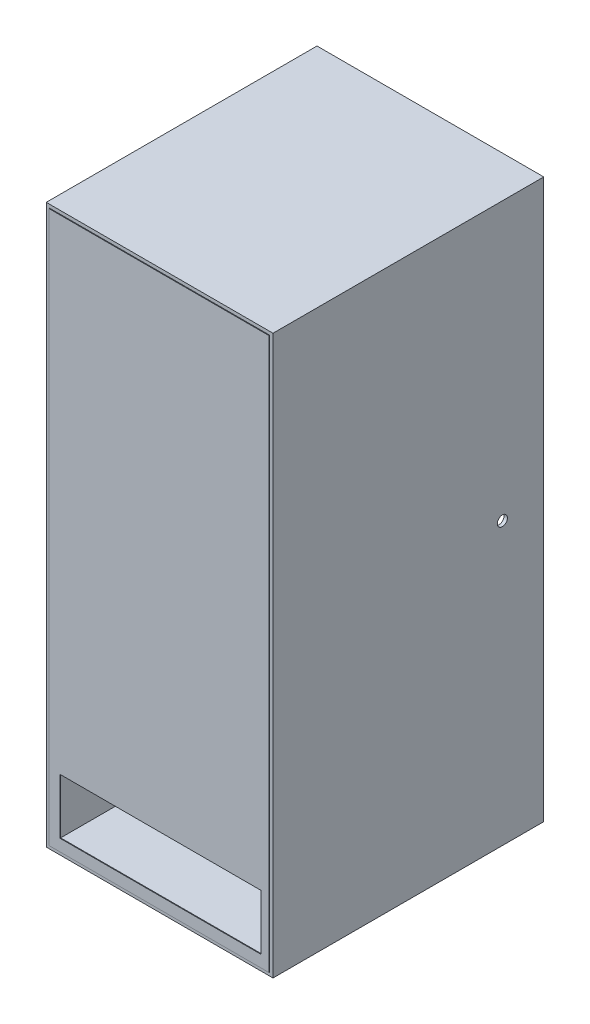
from build123d import *

# Parameters (mm, degrees)
SKETCH2_W           = 67
SKETCH2_H           = 165
SKETCH2_W_2         = 65
SKETCH2_H_2         = 163
EXTRUDE_THIN1_DEPTH = 80
SKETCH3_W           = 65
SKETCH3_H           = 163
BOSS_EXTRUDE1_DEPTH = 0.2
SKETCH7_W           = 62.114238051
SKETCH7_H           = 19.14674024
SKETCH7_W_2         = 60.114238051
SKETCH7_H_2         = 17.14674024
EXTRUDE_THIN7_DEPTH = 60
SKETCH8_W           = 23.60764342
SKETCH8_H           = 56.279229241
CUT_EXTRUDE1_DEPTH  = 10
SKETCH9_W           = 59.357592206
SKETCH9_H           = 16.357775012
CUT_EXTRUDE2_DEPTH  = 10
SKETCH10_R          = 1.5
CUT_EXTRUDE3_DEPTH  = 20


with BuildPart() as part:
    # Sketch2 → Extrude-Thin1 (new body)
    with BuildSketch(Plane.XY):
        with Locations((-14.463197467, 38.32)):
            Rectangle(SKETCH2_W, SKETCH2_H)
        with Locations((-14.463197467, 38.32)):
            Rectangle(SKETCH2_W_2, SKETCH2_H_2, mode=Mode.SUBTRACT)
    extrude(amount=EXTRUDE_THIN1_DEPTH)

    # Sketch10 → Cut-Extrude3 (cut)
    with BuildSketch(Plane(origin=(19.036802533, 0, 0), x_dir=(0, 0, -1), z_dir=(1, 0, 0))):
        with Locations((-12.220104164, 38.92992837)):
            Circle(SKETCH10_R)
    extrude(amount=-CUT_EXTRUDE3_DEPTH, mode=Mode.SUBTRACT)


with BuildPart() as body_2:
    # Sketch3 → Boss-Extrude1 (new body)
    with BuildSketch(Plane.XY.offset(80)):
        with Locations((-14.463197467, 38.32)):
            Rectangle(SKETCH3_W, SKETCH3_H)
    extrude(amount=BOSS_EXTRUDE1_DEPTH)

    # Sketch7 → Extrude-Thin7 (add)
    with BuildSketch(Plane.XY.offset(80.2)):
        with Locations((-14.025735507, -31.49245653)):
            Rectangle(SKETCH7_W, SKETCH7_H)
        with Locations((-14.025735507, -31.49245653)):
            Rectangle(SKETCH7_W_2, SKETCH7_H_2, mode=Mode.SUBTRACT)
    extrude(amount=-EXTRUDE_THIN7_DEPTH)

    # Sketch8 → Cut-Extrude1 (cut)
    with BuildSketch(Plane(origin=(0, -21.91908641, 0), x_dir=(1, 0, 0), z_dir=(0, 1, 0))):
        with Locations((-17.37740118, -48.339614621)):
            Rectangle(SKETCH8_W, SKETCH8_H)
    extrude(amount=-CUT_EXTRUDE1_DEPTH, mode=Mode.SUBTRACT)

    # Sketch9 → Cut-Extrude2 (cut)
    with BuildSketch(Plane(origin=(0, 0, 80), x_dir=(-1, 0, 0), z_dir=(0, 0, -1))):
        with Locations((14.014495431, -31.506928236)):
            Rectangle(SKETCH9_W, SKETCH9_H)
    extrude(amount=-CUT_EXTRUDE2_DEPTH, mode=Mode.SUBTRACT)


solid = Compound([part.part, body_2.part])
